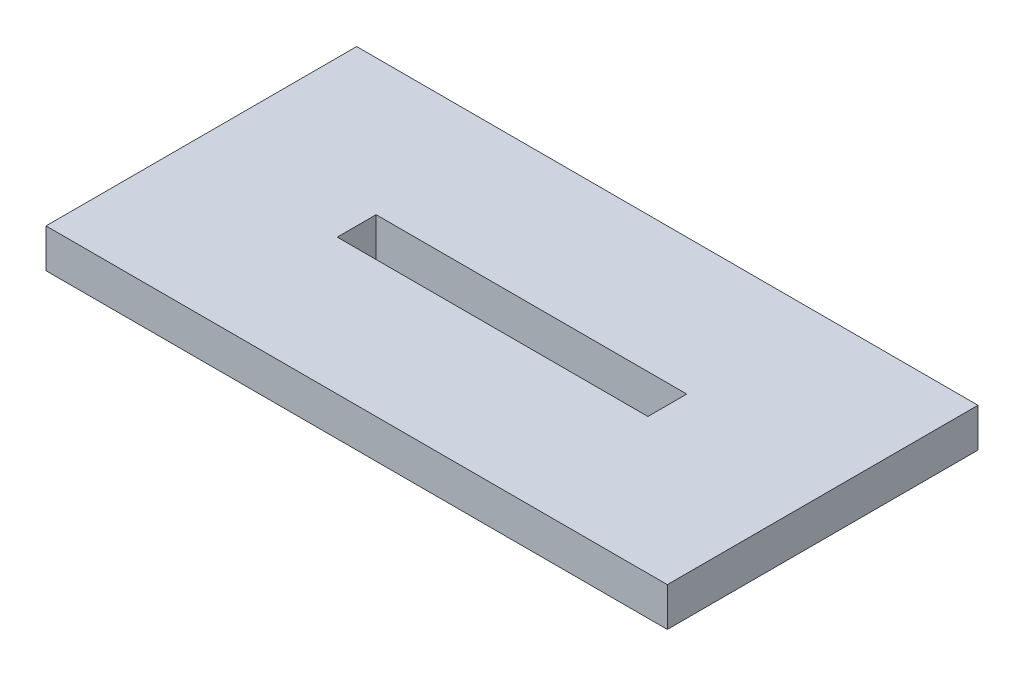
from build123d import *

# Parameters (mm, degrees)
SKETCH1_W           = 50.8
SKETCH1_H           = 25.4
SKETCH1_W_2         = 25.4
SKETCH1_H_2         = 3.175
BOSS_EXTRUDE1_DEPTH = 3.175


with BuildPart() as part:
    # Sketch1 → Boss-Extrude1 (new body)
    with BuildSketch(Plane(origin=(0, 0, 0), x_dir=(1, 0, 0), z_dir=(0, 1, 0))):
        Rectangle(SKETCH1_W, SKETCH1_H)
        Rectangle(SKETCH1_W_2, SKETCH1_H_2, mode=Mode.SUBTRACT)
    extrude(amount=BOSS_EXTRUDE1_DEPTH)


solid = part.part
